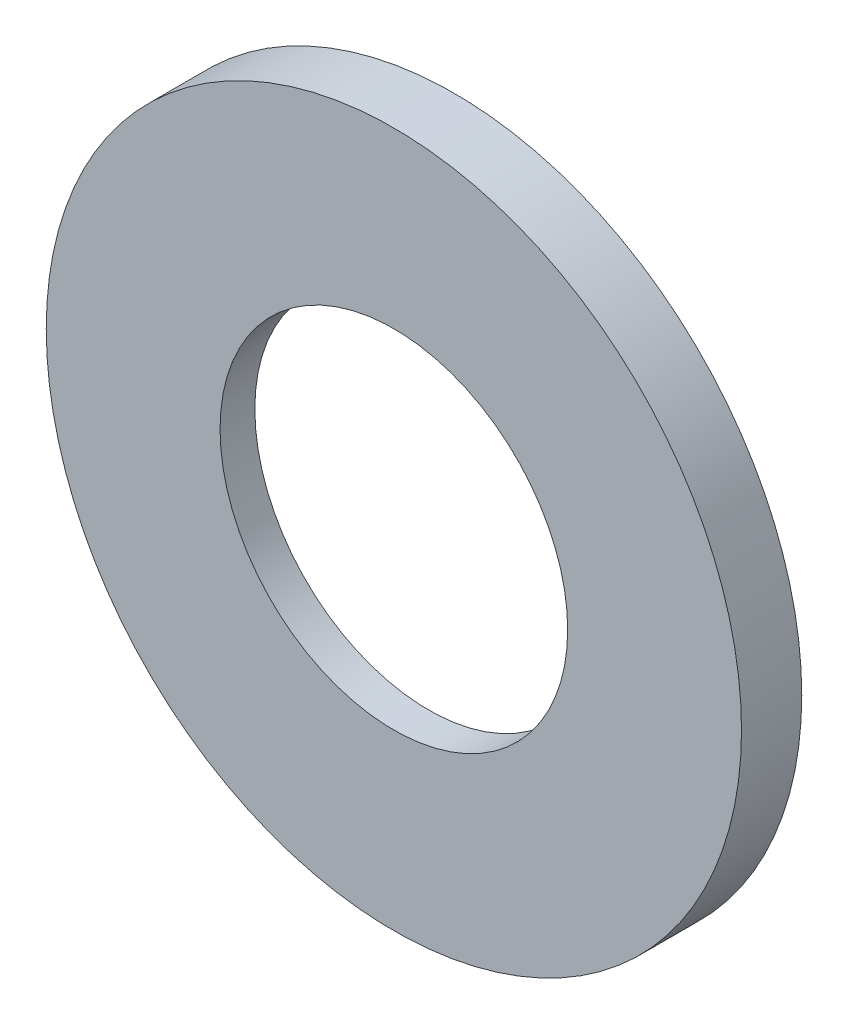
from build123d import *

# Parameters (mm, degrees)
ESQUISSE1_R             = 75
ESQUISSE1_R_2           = 52.5
BOSS_EXTRU_1_DEPTH      = 30
ESQUISSE2_R             = 52.5
ESQUISSE2_R_2           = 37.5
BOSS_EXTRU_2_DEPTH      = 19.5
ESQUISSE3_R             = 42.5
ESQUISSE3_R_2           = 37.5
BOSS_EXTRU_3_DEPTH      = 5
ESQUISSE4_R             = 75
ESQUISSE4_R_2           = 37.5
ENL_V_MAT_EXTRU_1_DEPTH = 17


with BuildPart() as part:
    # Esquisse1 → Boss.-Extru.1 (new body)
    with BuildSketch(Plane.XY):
        Circle(ESQUISSE1_R)
        Circle(ESQUISSE1_R_2, mode=Mode.SUBTRACT)
    extrude(amount=BOSS_EXTRU_1_DEPTH)

    # Esquisse2 → Boss.-Extru.2 (add)
    with BuildSketch(Plane.XY.offset(30)):
        Circle(ESQUISSE2_R)
        Circle(ESQUISSE2_R_2, mode=Mode.SUBTRACT)
    extrude(amount=-BOSS_EXTRU_2_DEPTH)

    # Esquisse3 → Boss.-Extru.3 (add)
    with BuildSketch(Plane(origin=(0, 0, 10.5), x_dir=(-1, 0, 0), z_dir=(0, 0, -1))):
        with Locations(Location((0, 0, 0), (0, 0, 180))):
            Circle(ESQUISSE3_R)
        with Locations(Location((0, 0, 0), (0, 0, 180))):
            Circle(ESQUISSE3_R_2, mode=Mode.SUBTRACT)
    extrude(amount=BOSS_EXTRU_3_DEPTH)

    # Esquisse4 → Enlèv. mat.-Extru.1 (cut)
    with BuildSketch(Plane.XY.offset(30)):
        Circle(ESQUISSE4_R)
        Circle(ESQUISSE4_R_2, mode=Mode.SUBTRACT)
    extrude(amount=-ENL_V_MAT_EXTRU_1_DEPTH, mode=Mode.SUBTRACT)


solid = part.part
